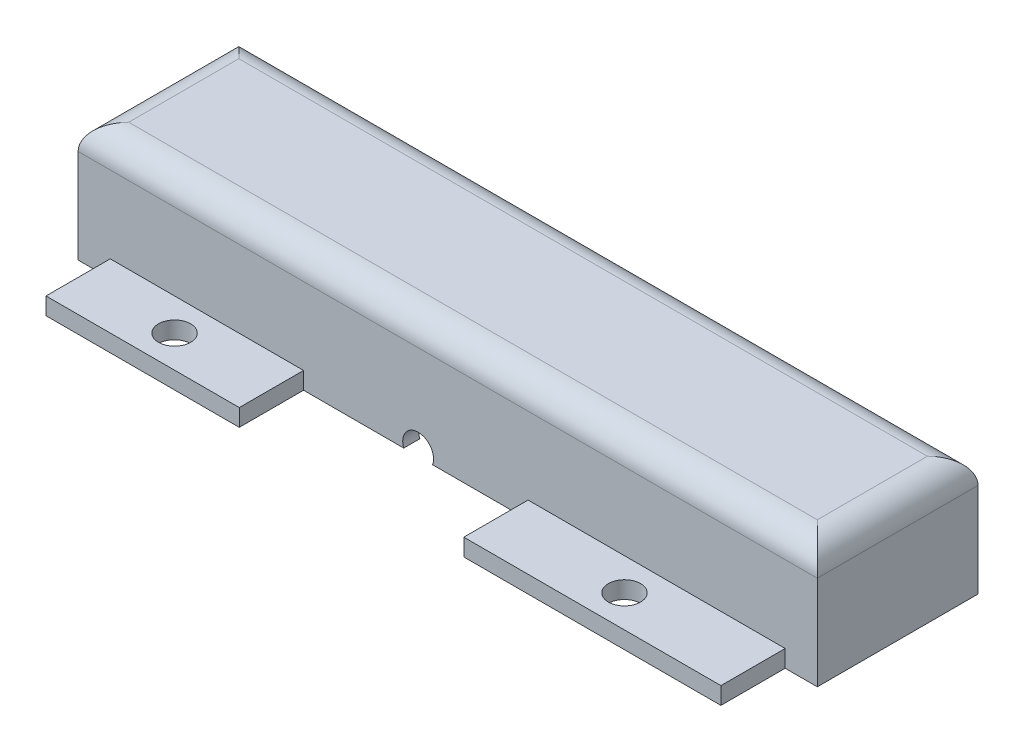
from build123d import *

# Parameters (mm, degrees)
SKETCH1_W           = 146.05
SKETCH1_H           = 23.59
BOSS_EXTRUDE1_DEPTH = 31.75
SKETCH2_W           = 139.69
SKETCH2_H           = 25.39
CUT_EXTRUDE1_DEPTH  = 21
FILLET1_R           = 5
SKETCH3_R           = 3.05
CUT_EXTRUDE2_DEPTH  = 3.18
SKETCH4_W           = 38.19
SKETCH4_H           = 3.39
SKETCH4_W_2         = 50.8
BOSS_EXTRUDE2_DEPTH = 12.7
SKETCH5_W           = 25.4
SKETCH5_H           = 3.39
BOSS_EXTRUDE3_DEPTH = 12.7
SKETCH6_R           = 3.175
CUT_EXTRUDE3_DEPTH  = 12.7
SKETCH7_R           = 3.175
CUT_EXTRUDE4_DEPTH  = 12.7


with BuildPart() as part:
    # Sketch1 → Boss-Extrude1 (new body)
    with BuildSketch(Plane.XY):
        with Locations((25.404065421, 11.795)):
            Rectangle(SKETCH1_W, SKETCH1_H)
    extrude(amount=BOSS_EXTRUDE1_DEPTH)

    # Sketch2 → Cut-Extrude1 (cut)
    with BuildSketch(Plane.XZ):
        with Locations((25.404065421, 15.875)):
            Rectangle(SKETCH2_W, SKETCH2_H)
    extrude(amount=-CUT_EXTRUDE1_DEPTH, mode=Mode.SUBTRACT)

    # Fillet1
    fillet1_edges = [part.edges().sort_by_distance(p)[0] for p in [
        (25.404065421, 23.59, 31.75),
        (25.404065421, 23.59, 0),
        (-47.620934579, 23.59, 15.875),
        (98.429065421, 23.59, 15.875),
    ]]
    fillet(fillet1_edges, radius=FILLET1_R)

    # Sketch3 → Cut-Extrude2 (cut)
    with BuildSketch(Plane.XY.offset(31.75)):
        with Locations((19.559065421, 1.09)):
            Circle(SKETCH3_R)
    extrude(amount=-CUT_EXTRUDE2_DEPTH, mode=Mode.SUBTRACT)

    # Sketch4 → Boss-Extrude2 (add)
    with BuildSketch(Plane.XY.offset(31.75)):
        with Locations((-22.175934579, 1.695)):
            Rectangle(SKETCH4_W, SKETCH4_H)
        with Locations((66.679065421, 1.695)):
            Rectangle(SKETCH4_W_2, SKETCH4_H)
    extrude(amount=BOSS_EXTRUDE2_DEPTH)

    # Sketch5 → Boss-Extrude3 (add)
    with BuildSketch(Plane(origin=(0, 0, 0), x_dir=(-1, 0, 0), z_dir=(0, 0, -1))):
        with Locations((-25.729065421, 1.695)):
            Rectangle(SKETCH5_W, SKETCH5_H)
    extrude(amount=BOSS_EXTRUDE3_DEPTH)

    # Sketch6 → Cut-Extrude3 (cut)
    with BuildSketch(Plane(origin=(0, 3.39, 0), x_dir=(1, 0, 0), z_dir=(0, 1, 0))):
        with Locations((-22.220934579, -38.1)):
            Circle(SKETCH6_R)
        with Locations((66.679065421, -38.1)):
            Circle(SKETCH6_R)
    extrude(amount=-CUT_EXTRUDE3_DEPTH, mode=Mode.SUBTRACT)

    # Sketch7 → Cut-Extrude4 (cut)
    with BuildSketch(Plane(origin=(0, 3.39, 0), x_dir=(1, 0, 0), z_dir=(0, 1, 0))):
        with Locations((25.729065421, 6.35)):
            Circle(SKETCH7_R)
    extrude(amount=-CUT_EXTRUDE4_DEPTH, mode=Mode.SUBTRACT)


solid = part.part
